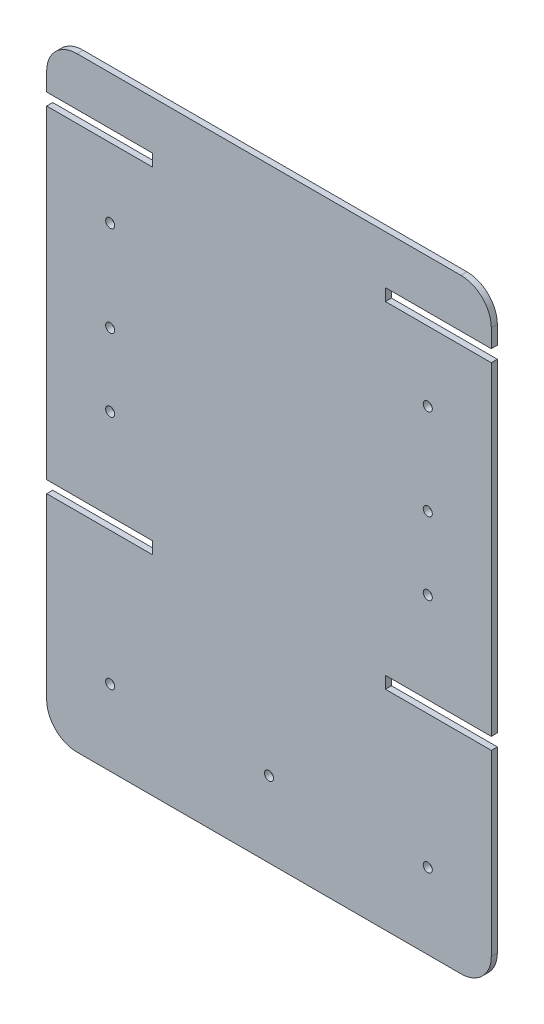
from build123d import *

# Parameters (mm, degrees)
RESSALTO_EXTRUS_O1_DEPTH = 2
ESBO_O2_R                = 1.5
CORTE_EXTRUS_O1_DEPTH    = 2


with BuildPart() as part:
    # Esboço1 → Ressalto-extrusão1 (new body)
    with BuildSketch(Plane.XY):
        with BuildLine():
            Line((-73.5, -27), (-73.5, 80))
            Line((-73.5, 80), (-38.5, 80))
            Line((-38.5, 80), (-38.5, 84))
            Line((-38.5, 84), (-73.5, 84))
            Line((-73.5, 84), (-73.5, 90))
            ThreePointArc((-73.5, 90), (-70.571067812, 97.071067812), (-63.5, 100))
            Line((-63.5, 100), (63.5, 100))
            ThreePointArc((63.5, 100), (70.571067812, 97.071067812), (73.5, 90))
            Line((73.5, 90), (73.5, 84))
            Line((73.5, 84), (38.5, 84))
            Line((38.5, 84), (38.5, 80))
            Line((38.5, 80), (73.5, 80))
            Line((73.5, 80), (73.5, -27))
            Line((73.5, -27), (38.5, -27))
            Line((38.5, -27), (38.5, -31))
            Line((38.5, -31), (73.5, -31))
            Line((73.5, -31), (73.5, -90))
            ThreePointArc((73.5, -90), (70.571067812, -97.071067812), (63.5, -100))
            Line((63.5, -100), (-63.5, -100))
            ThreePointArc((-63.5, -100), (-70.571067812, -97.071067812), (-73.5, -90))
            Line((-73.5, -90), (-73.5, -31))
            Line((-73.5, -31), (-38.5, -31))
            Line((-38.5, -31), (-38.5, -27))
            Line((-38.5, -27), (-73.5, -27))
        make_face()
    extrude(amount=RESSALTO_EXTRUS_O1_DEPTH)

    # Esboço2 → Corte-extrusão1 (cut)
    with BuildSketch(Plane.XY.offset(2)):
        with Locations((-52.5, 57)):
            Circle(ESBO_O2_R)
        with Locations((-52.5, 27)):
            Circle(ESBO_O2_R)
        with Locations((-52.5, 3)):
            Circle(ESBO_O2_R)
        with Locations((-52.5, -75)):
            Circle(ESBO_O2_R)
        with Locations((52.5, 57)):
            Circle(ESBO_O2_R)
        with Locations((52.5, -75)):
            Circle(ESBO_O2_R)
        with Locations((52.5, 3)):
            Circle(ESBO_O2_R)
        with Locations((52.5, 27)):
            Circle(ESBO_O2_R)
        with Locations((0, -75)):
            Circle(ESBO_O2_R)
    extrude(amount=-CORTE_EXTRUS_O1_DEPTH, mode=Mode.SUBTRACT)


solid = part.part
